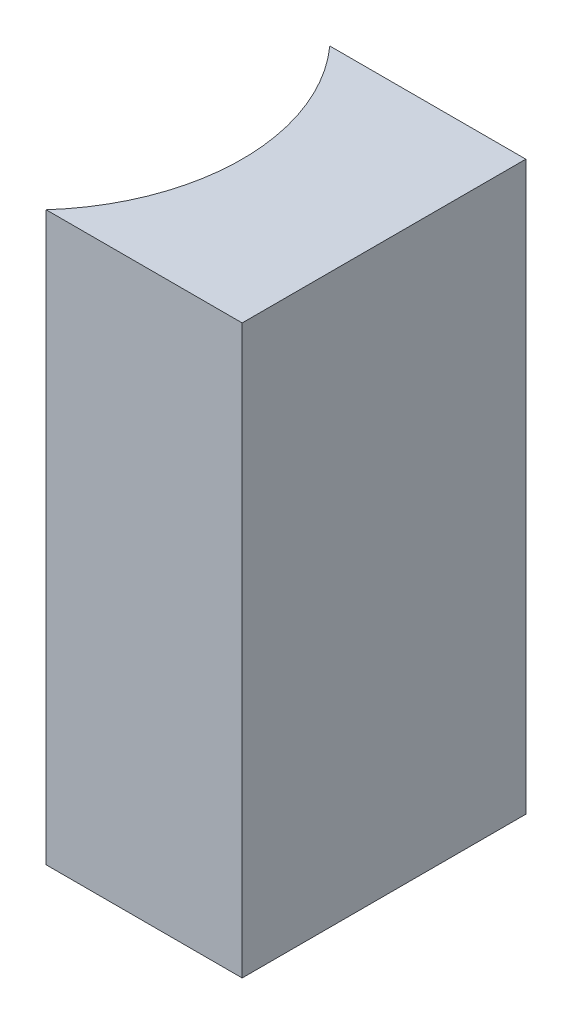
from build123d import *

# Parameters (mm, degrees)
EXTRUDE_1_DEPTH = 8


with BuildPart() as part:
    # 草图1 → 凸台-拉伸1 (new body)
    with BuildSketch(Plane(origin=(0, 0, 0), x_dir=(1, 0, 0), z_dir=(0, 1, 0))):
        with BuildLine():
            Line((0, 0), (0, -4))
            Line((0, -4), (-2.763932023, -4))
            ThreePointArc((-2.763932023, -4), (-2, -2), (-2.763932023, 0))
            Line((-2.763932023, 0), (0, 0))
        make_face()
    extrude(amount=EXTRUDE_1_DEPTH)


solid = part.part
